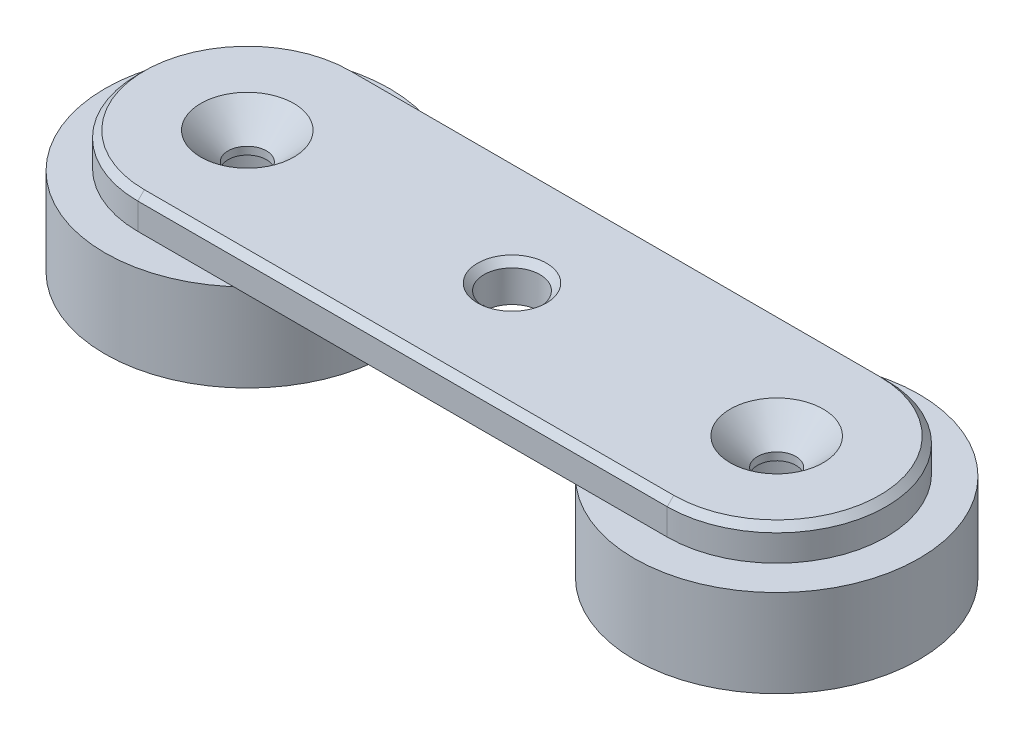
from build123d import *

# Parameters (mm, degrees)
SKETCH1_R            = 2.55
BOSS_EXTRUDE1_DEPTH  = 3
SKETCH10_R           = 7.5
BOSS_EXTRUDE6_DEPTH  = 0.2
SKETCH11_R           = 5.05
BOSS_EXTRUDE8_DEPTH  = 8
SKETCH12_R           = 13
SKETCH12_R_2         = 5
BOSS_EXTRUDE9_DEPTH  = 8
SKETCH13_R           = 1.25
CUT_EXTRUDE6_DEPTH   = 12.2
SKETCH14_R           = 2.55
SKETCH14_R_2         = 1.75
BOSS_EXTRUDE10_DEPTH = 3
SKETCH15_R           = 7.5
SKETCH15_R_2         = 1.75
BOSS_EXTRUDE11_DEPTH = 0.2
CHAMFER1_SIZE        = 2.5
CHAMFER2_SIZE        = 0.6
BOSS_EXTRUDE12_DEPTH = 0.5
BOSS_EXTRUDE13_DEPTH = 0.5
CHAMFER3_SIZE        = 0.6


with BuildPart() as part:
    # Sketch1 → Boss-Extrude1 (new body)
    with BuildSketch(Plane(origin=(0, 0, 0), x_dir=(1, 0, 0), z_dir=(0, 1, 0))):
        with BuildLine():
            Line((24.175, -10), (-24.175, -10))
            ThreePointArc((-24.175, -10), (-34.175, 0), (-24.175, 10))
            Line((-24.175, 10), (24.175, 10))
            ThreePointArc((24.175, 10), (34.175, 0), (24.175, -10))
        make_face()
        Circle(SKETCH1_R, mode=Mode.SUBTRACT)
    extrude(amount=BOSS_EXTRUDE1_DEPTH)

    # Sketch10 → Boss-Extrude6 (add)
    with BuildSketch(Plane(origin=(0, 3, 0), x_dir=(1, 0, 0), z_dir=(0, 1, 0))):
        with Locations((-24.175, 0)):
            Circle(SKETCH10_R)
        with Locations((24.175, 0)):
            Circle(SKETCH10_R)
    extrude(amount=BOSS_EXTRUDE6_DEPTH)

    # Sketch11 → Boss-Extrude8 (add)
    with BuildSketch(Plane(origin=(0, 3.2, 0), x_dir=(1, 0, 0), z_dir=(0, 1, 0))):
        with Locations((-24.175, 0)):
            Circle(SKETCH11_R)
        with Locations((24.175, 0)):
            Circle(SKETCH11_R)
    extrude(amount=BOSS_EXTRUDE8_DEPTH)

    # Sketch13 → Cut-Extrude6 (cut, through all)
    with BuildSketch(Plane(origin=(0, 11.2, 0), x_dir=(1, 0, 0), z_dir=(0, 1, 0))):
        with Locations((-24.175, 0)):
            Circle(SKETCH13_R)
        with Locations((24.175, 0)):
            Circle(SKETCH13_R)
    extrude(amount=-CUT_EXTRUDE6_DEPTH, mode=Mode.SUBTRACT)

    # Sketch16 → Boss-Extrude12 (add)
    with BuildSketch(Plane(origin=(0, 3, 0), x_dir=(1, 0, 0), z_dir=(0, 1, 0))):
        with BuildLine():
            Line((-10, 0), (-2.55, 0))
            ThreePointArc((-2.55, 0), (0, 2.55), (2.55, 0))
            Line((2.55, 0), (10, 0))
            ThreePointArc((10, 0), (0, 10), (-10, 0))
        make_face()
    extrude(amount=BOSS_EXTRUDE12_DEPTH)

    # Chamfer3
    chamfer3_edges = [part.edges().sort_by_distance(p)[0] for p in [
        (-2.55, 0, 0),
        (-25.425, 0, 0),
        (22.925, 0, 0),
        (0, 0, 10),
        (-34.175, 0, 0),
        (0, 0, -10),
        (34.175, 0, 0),
    ]]
    chamfer(chamfer3_edges, length=CHAMFER3_SIZE)


with BuildPart() as body_2:
    # Sketch12 → Boss-Extrude9 (new body)
    with BuildSketch(Plane(origin=(0, 3.2, 0), x_dir=(1, 0, 0), z_dir=(0, 1, 0))):
        with Locations((-24.175, 0)):
            Circle(SKETCH12_R)
        with Locations((-24.175, 0)):
            Circle(SKETCH12_R_2, mode=Mode.SUBTRACT)
    extrude(amount=BOSS_EXTRUDE9_DEPTH)


with BuildPart() as body_3:
    # Mirror3: mirrored copy
    add(body_2.part.mirror(Plane(origin=(0, 0, 0), x_dir=(0, 0, 1), z_dir=(1, 0, 0))))


with BuildPart() as body_4:
    # Sketch14 → Boss-Extrude10 (new body)
    with BuildSketch(Plane(origin=(0, 11.4, 0), x_dir=(1, 0, 0), z_dir=(0, 1, 0))):
        with BuildLine():
            Line((-24.175, -10), (24.175, -10))
            ThreePointArc((24.175, -10), (34.175, 0), (24.175, 10))
            Line((24.175, 10), (-24.175, 10))
            ThreePointArc((-24.175, 10), (-34.175, 0), (-24.175, -10))
        make_face()
        Circle(SKETCH14_R, mode=Mode.SUBTRACT)
        with Locations((-24.175, 0)):
            Circle(SKETCH14_R_2, mode=Mode.SUBTRACT)
        with Locations((24.175, 0)):
            Circle(SKETCH14_R_2, mode=Mode.SUBTRACT)
    extrude(amount=BOSS_EXTRUDE10_DEPTH)

    # Sketch15 → Boss-Extrude11 (add)
    with BuildSketch(Plane.XZ.offset(-11.4)):
        with Locations((24.175, 0)):
            Circle(SKETCH15_R)
        with Locations((24.175, 0)):
            Circle(SKETCH15_R_2, mode=Mode.SUBTRACT)
        with Locations((-24.175, 0)):
            Circle(SKETCH15_R)
        with Locations((-24.175, 0)):
            Circle(SKETCH15_R_2, mode=Mode.SUBTRACT)
    extrude(amount=BOSS_EXTRUDE11_DEPTH)

    # Chamfer1
    chamfer1_edges = [body_4.edges().sort_by_distance(p)[0] for p in [
        (-25.925, 14.4, 0),
        (22.425, 14.4, 0),
    ]]
    chamfer(chamfer1_edges, length=CHAMFER1_SIZE)

    # Chamfer2
    chamfer2_edges = [body_4.edges().sort_by_distance(p)[0] for p in [
        (-34.175, 14.4, 0),
        (-2.55, 14.4, 0),
        (0, 14.4, 10),
        (34.175, 14.4, 0),
        (0, 14.4, -10),
    ]]
    chamfer(chamfer2_edges, length=CHAMFER2_SIZE)

    # Sketch17 → Boss-Extrude13 (add)
    with BuildSketch(Plane.XZ.offset(-11.4)):
        with BuildLine():
            Line((-2.55, 0), (-10, 0))
            ThreePointArc((-10, 0), (0, -10), (10, 0))
            Line((10, 0), (2.55, 0))
            ThreePointArc((2.55, 0), (0, -2.55), (-2.55, 0))
        make_face()
    extrude(amount=BOSS_EXTRUDE13_DEPTH)


solid = Compound([body_2.part, body_3.part, body_4.part])
